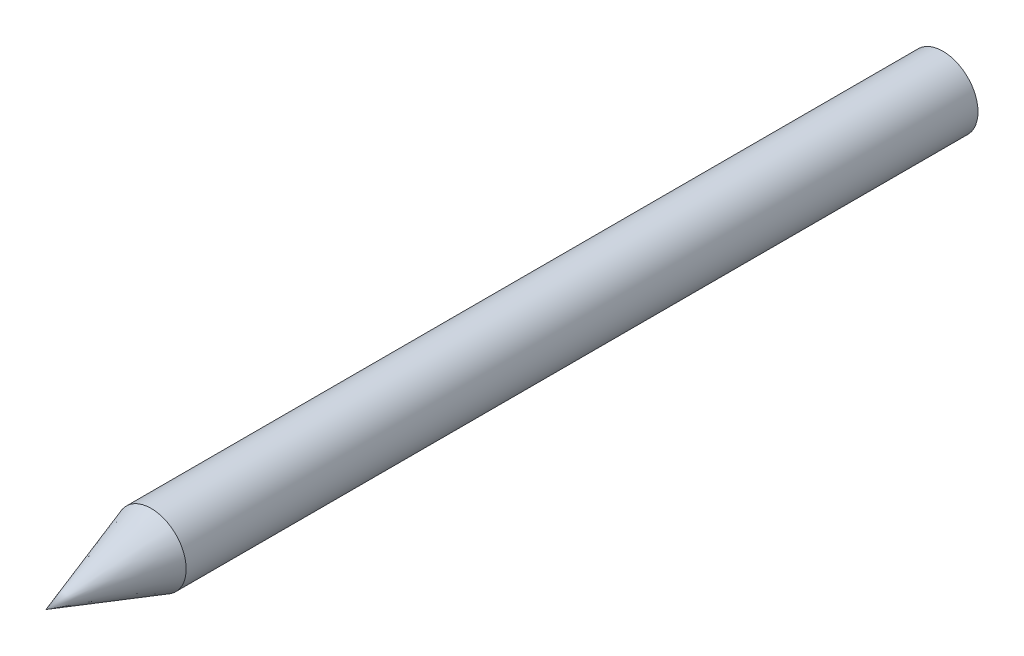
from build123d import *

# Parameters (mm, degrees)
ESQUISSE1_R        = 5
BOSS_EXTRU_1_DEPTH = 128
CHANFREIN1_SIZE    = 15
CHANFREIN1_SIZE2   = 5


with BuildPart() as part:
    # Esquisse1 → Boss.-Extru.1 (new body)
    with BuildSketch(Plane.XY):
        Circle(ESQUISSE1_R)
    extrude(amount=BOSS_EXTRU_1_DEPTH)

    # Chanfrein1
    chanfrein1_edges = [part.edges().sort_by_distance(p)[0] for p in [
        (-5, 0, 128),
    ]]
    chanfrein1_side = [part.faces().sort_by_distance(p)[0] for p in [
        (-5, 0, 64),
    ]]
    chamfer(chanfrein1_edges, length=CHANFREIN1_SIZE, length2=CHANFREIN1_SIZE2, reference=chanfrein1_side[0])


solid = part.part
